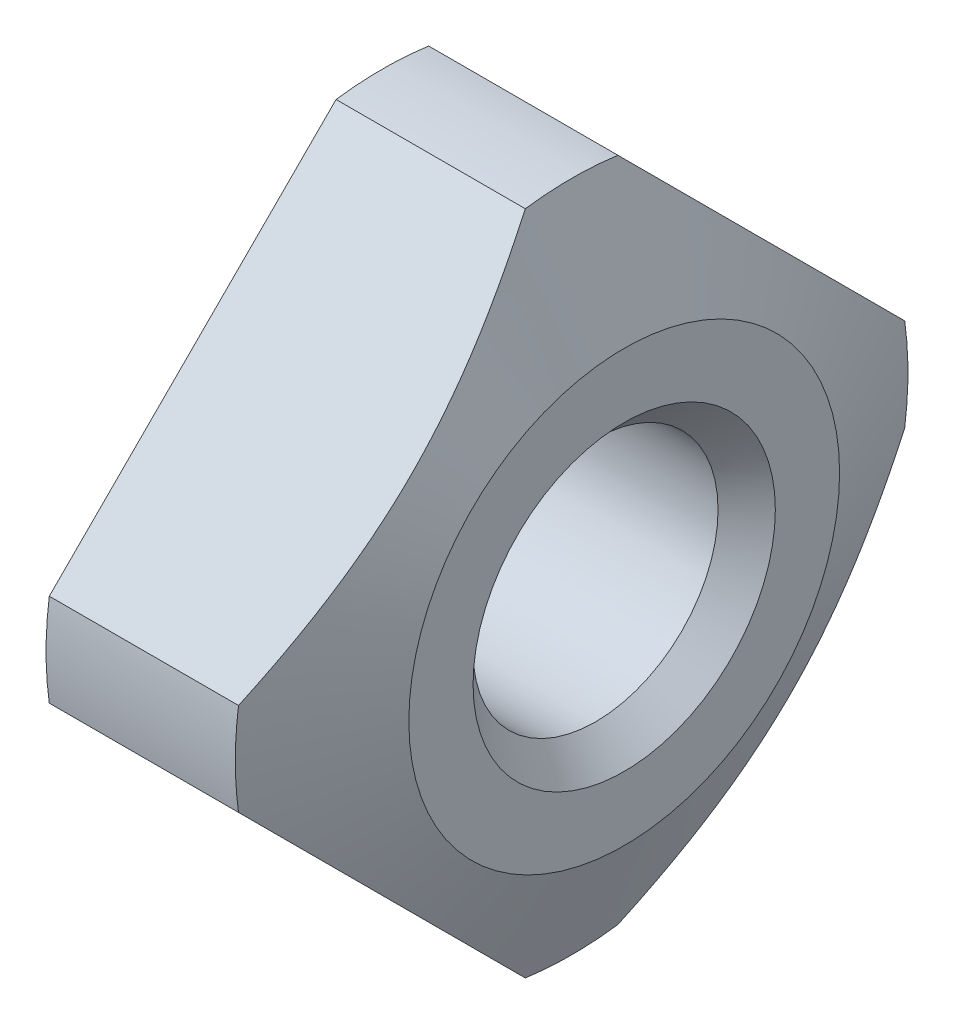
from build123d import *

# Parameters (mm, degrees)
SKETCH2_W          = 28
SKETCH2_H          = 28
CUT_EXTRUDE1_DEPTH = 3.2
SKETCH4_W          = 14
SKETCH4_H          = 14
SKETCH4_R          = 4.45
CUT_EXTRUDE2_DEPTH = 3.2


with BuildPart() as part:
    # Sketch1 → Revolve1 (revolve)
    with BuildSketch(Plane.XY):
        Polygon((0, 0), (0, 4.949747468), (2.287003816, 4.949747468), (3.2, 2.85), (3.2, 0), align=None)
    revolve(axis=Axis((3.2, 0, 0), (-1, 0, 0)))

    # Sketch2 → Cut-Extrude1 (cut)
    with BuildSketch(Plane(origin=(0, 0, 0), x_dir=(0, 0, -1), z_dir=(1, 0, 0))):
        Rectangle(SKETCH2_W, SKETCH2_H)
        Polygon((-5.020458146, 0), (0, -5.020458146), (5.020458146, 0), (0, 5.020458146), align=None, mode=Mode.SUBTRACT)
    extrude(amount=CUT_EXTRUDE1_DEPTH, mode=Mode.SUBTRACT)

    # Sketch3 → Cut-Revolve1 (revolve, cut)
    with BuildSketch(Plane.XY):
        Polygon((0, 0), (0, 2), (0.379, 1.621), (2.821, 1.621), (3.2, 2), (3.2, 0), align=None)
    revolve(axis=Axis((3.2, 0, 0), (-1, 0, 0)), mode=Mode.SUBTRACT)

    # Sketch4 → Cut-Extrude2 (cut)
    with BuildSketch(Plane(origin=(0, 0, 0), x_dir=(0, 0, -1), z_dir=(1, 0, 0))):
        Rectangle(SKETCH4_W, SKETCH4_H)
        Circle(SKETCH4_R, mode=Mode.SUBTRACT)
    extrude(amount=CUT_EXTRUDE2_DEPTH, mode=Mode.SUBTRACT)


solid = part.part
